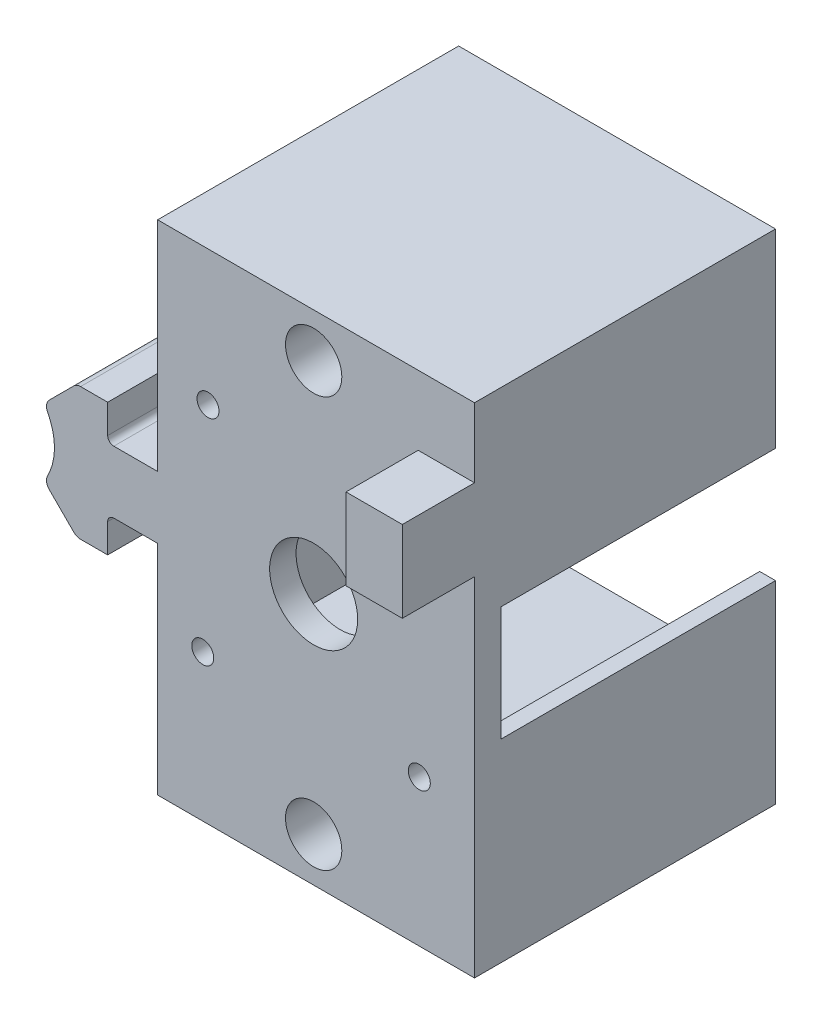
from build123d import *

# Parameters (mm, degrees)
BOSS_EXTRUDE1_DEPTH = 43.434
SKETCH3_W           = 3.81
SKETCH3_H           = 46.482
BOSS_EXTRUDE2_DEPTH = 43.688
BOSS_EXTRUDE5_DEPTH = 39.624
SKETCH9_R           = 6.35
CUT_EXTRUDE1_DEPTH  = 44.434
SKETCH10_R          = 1.5875
CUT_EXTRUDE2_DEPTH  = 4.81
SKETCH12_W          = 45.72
SKETCH12_H          = 43.434
BOSS_EXTRUDE6_DEPTH = 12.7
SKETCH13_W          = 45.72
SKETCH13_H          = 43.434
BOSS_EXTRUDE7_DEPTH = 12.7
SKETCH14_R          = 4.064
CUT_EXTRUDE3_DEPTH  = 6.35
SKETCH15_W          = 8.127430184
SKETCH15_H          = 11.729450278
BOSS_EXTRUDE8_DEPTH = 10.414


with BuildPart() as part:
    # Sketch2 → Boss-Extrude1 (new body)
    with BuildSketch(Plane.XY.offset(816.492372385)):
        with BuildLine():
            Line((35.750095932, 34.097582937), (35.750095932, 33.285263123))
            ThreePointArc((35.750095932, 33.285263123), (35.457981836, 31.445408446), (34.772439624, 29.71323416))
            ThreePointArc((34.772439624, 29.71323416), (34.62798184, 28.864383796), (35.01595222, 28.095687512))
            Line((35.01595222, 28.095687512), (38.55890274, 24.552736992))
            ThreePointArc((38.55890274, 24.552736992), (39.005633691, 24.254240914), (39.532588778, 24.14942303))
            Line((39.532588778, 24.14942303), (43.443796213, 24.14942303))
            Line((43.443796213, 24.14942303), (43.443796213, 28.31442303))
            ThreePointArc((43.443796213, 28.31442303), (43.703006711, 28.940212531), (44.328796213, 29.19942303))
            Line((44.328796213, 29.19942303), (48.113296213, 29.19942303))
            Line((48.113296213, 29.19942303), (50.653296213, 29.19942303))
            Line((50.653296213, 29.19942303), (50.653296213, 10.45042303))
            Line((50.653296213, 10.45042303), (52.685296213, 10.45042303))
            Line((52.685296213, 10.45042303), (52.685296213, 56.93242303))
            Line((52.685296213, 56.93242303), (50.653296213, 56.93242303))
            Line((50.653296213, 56.93242303), (50.653296213, 38.18342303))
            Line((50.653296213, 38.18342303), (48.113296213, 38.18342303))
            Line((48.113296213, 38.18342303), (44.328796213, 38.18342303))
            ThreePointArc((44.328796213, 38.18342303), (43.703006711, 38.442633529), (43.443796213, 39.06842303))
            Line((43.443796213, 39.06842303), (43.443796213, 43.23342303))
            Line((43.443796213, 43.23342303), (39.532588778, 43.23342303))
            ThreePointArc((39.532588778, 43.23342303), (39.005633691, 43.128605146), (38.55890274, 42.830109068))
            Line((38.55890274, 42.830109068), (35.01595222, 39.287158548))
            ThreePointArc((35.01595222, 39.287158548), (34.62798184, 38.518462264), (34.772439624, 37.6696119))
            ThreePointArc((34.772439624, 37.6696119), (35.457981836, 35.937437615), (35.750095932, 34.097582937))
        make_face()
    extrude(amount=BOSS_EXTRUDE1_DEPTH)

    # Sketch3 → Boss-Extrude2 (add)
    with BuildSketch(Plane(origin=(52.685296213, 0, 0), x_dir=(0, 0, -1), z_dir=(1, 0, 0))):
        with Locations((-858.021372385, 33.69142303)):
            Rectangle(SKETCH3_W, SKETCH3_H)
    extrude(amount=BOSS_EXTRUDE2_DEPTH)

    # Sketch8 → Boss-Extrude5 (add)
    with BuildSketch(Plane(origin=(0, 0, 856.116372385), x_dir=(-1, 0, 0), z_dir=(0, 0, -1))):
        Polygon((-96.373296213, 56.93242303), (-52.685296213, 56.93242303), (-52.685296213, 54.90042303), (-94.087296213, 54.90042303), (-94.087296213, 42.220354744), (-96.373296213, 42.220354744), (-96.373296213, 54.90042303), align=None)
        Polygon((-96.373296213, 10.45042303), (-52.685296213, 10.45042303), (-52.685296213, 12.48242303), (-94.087296213, 12.48242303), (-94.087296213, 25.69042303), (-96.373296213, 25.69042303), (-96.373296213, 12.48242303), align=None)
    extrude(amount=BOSS_EXTRUDE5_DEPTH)

    # Sketch9 → Cut-Extrude1 (cut, through all)
    with BuildSketch(Plane.XY.offset(859.926372385)):
        with Locations((73.163747061, 34.125316724)):
            Circle(SKETCH9_R)
    extrude(amount=-CUT_EXTRUDE1_DEPTH, mode=Mode.SUBTRACT)

    # Sketch10 → Cut-Extrude2 (cut, through all)
    with BuildSketch(Plane(origin=(0, 0, 856.116372385), x_dir=(-1, 0, 0), z_dir=(0, 0, -1))):
        with Locations((-89.163747266, 50.124873673)):
            Circle(SKETCH10_R)
        with Locations((-57.921747266, 50.14642303)):
            Circle(SKETCH10_R)
        with Locations((-57.163746856, 18.90442303)):
            Circle(SKETCH10_R)
        with Locations((-88.405746856, 18.882873673)):
            Circle(SKETCH10_R)
    extrude(amount=-CUT_EXTRUDE2_DEPTH, mode=Mode.SUBTRACT)

    # Sketch12 → Boss-Extrude6 (add)
    with BuildSketch(Plane(origin=(0, 56.93242303, 0), x_dir=(1, 0, 0), z_dir=(0, 1, 0))):
        with Locations((73.513296213, -838.209372385)):
            Rectangle(SKETCH12_W, SKETCH12_H)
    extrude(amount=BOSS_EXTRUDE6_DEPTH)

    # Sketch13 → Boss-Extrude7 (add)
    with BuildSketch(Plane.XZ.offset(-10.45042303)):
        with Locations((73.513296213, 838.209372385)):
            Rectangle(SKETCH13_W, SKETCH13_H)
    extrude(amount=BOSS_EXTRUDE7_DEPTH)

    # Sketch14 → Cut-Extrude3 (cut)
    with BuildSketch(Plane.XY.offset(859.926372385)):
        with Locations((73.163747061, 63.28242303)):
            Circle(SKETCH14_R)
        with Locations((73.163747061, 4.10042303)):
            Circle(SKETCH14_R)
    extrude(amount=-CUT_EXTRUDE3_DEPTH, mode=Mode.SUBTRACT)

    # Sketch15 → Boss-Extrude8 (add)
    with BuildSketch(Plane.XY.offset(859.926372385)):
        with Locations((92.309581121, 53.763579533)):
            Rectangle(SKETCH15_W, SKETCH15_H)
    extrude(amount=BOSS_EXTRUDE8_DEPTH)


solid = part.part
